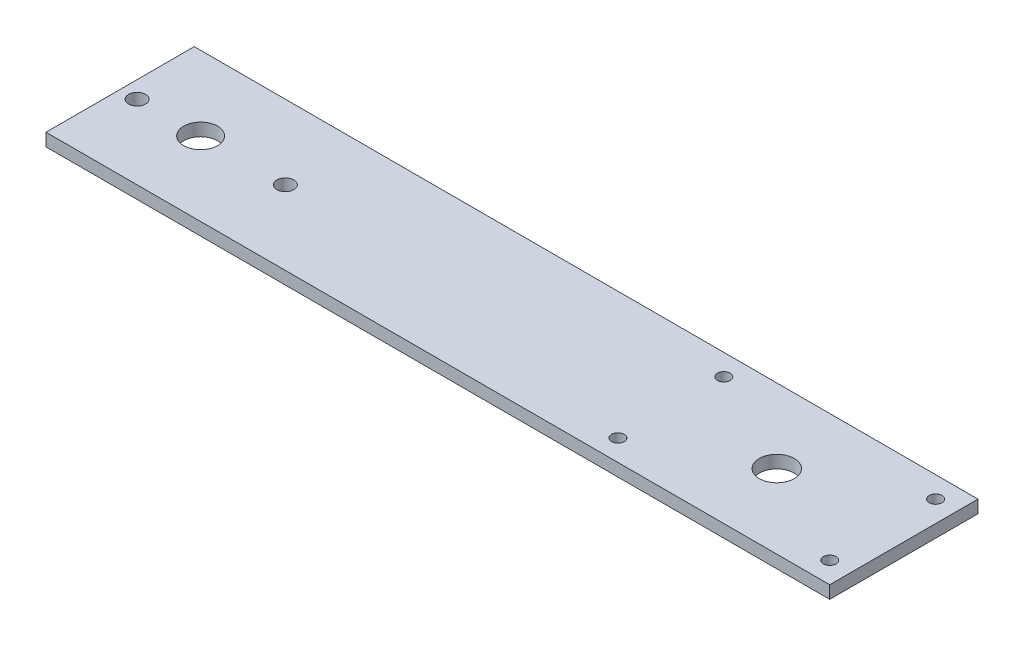
from build123d import *

# Parameters (mm, degrees)
SKETCH1_W           = 185
SKETCH1_H           = 35
SKETCH1_R           = 4.125
SKETCH1_R_2         = 2
SKETCH1_R_3         = 4
BOSS_EXTRUDE1_DEPTH = 3
SKETCH6_R           = 1.5
CUT_EXTRUDE6_DEPTH  = 4


with BuildPart() as part:
    # Sketch1 → Boss-Extrude1 (new body)
    with BuildSketch(Plane(origin=(0, 0, 0), x_dir=(1, 0, 0), z_dir=(0, 1, 0))):
        Rectangle(SKETCH1_W, SKETCH1_H)
        with Locations((62.5, 0)):
            Circle(SKETCH1_R, mode=Mode.SUBTRACT)
        with Locations((-88.5, 0)):
            Circle(SKETCH1_R_2, mode=Mode.SUBTRACT)
        with Locations((-53.5, 0)):
            Circle(SKETCH1_R_2, mode=Mode.SUBTRACT)
        with Locations((-73.5, 0)):
            Circle(SKETCH1_R_3, mode=Mode.SUBTRACT)
    extrude(amount=BOSS_EXTRUDE1_DEPTH)

    # Sketch6 → Cut-Extrude6 (cut, through all)
    with BuildSketch(Plane(origin=(0, 3, 0), x_dir=(1, 0, 0), z_dir=(0, 1, 0))):
        with Locations((87.5, 12.5)):
            Circle(SKETCH6_R)
        with Locations((87.5, -12.5)):
            Circle(SKETCH6_R)
        with Locations((37.5, -12.5)):
            Circle(SKETCH6_R)
        with Locations((37.5, 12.5)):
            Circle(SKETCH6_R)
    extrude(amount=-CUT_EXTRUDE6_DEPTH, mode=Mode.SUBTRACT)


solid = part.part
